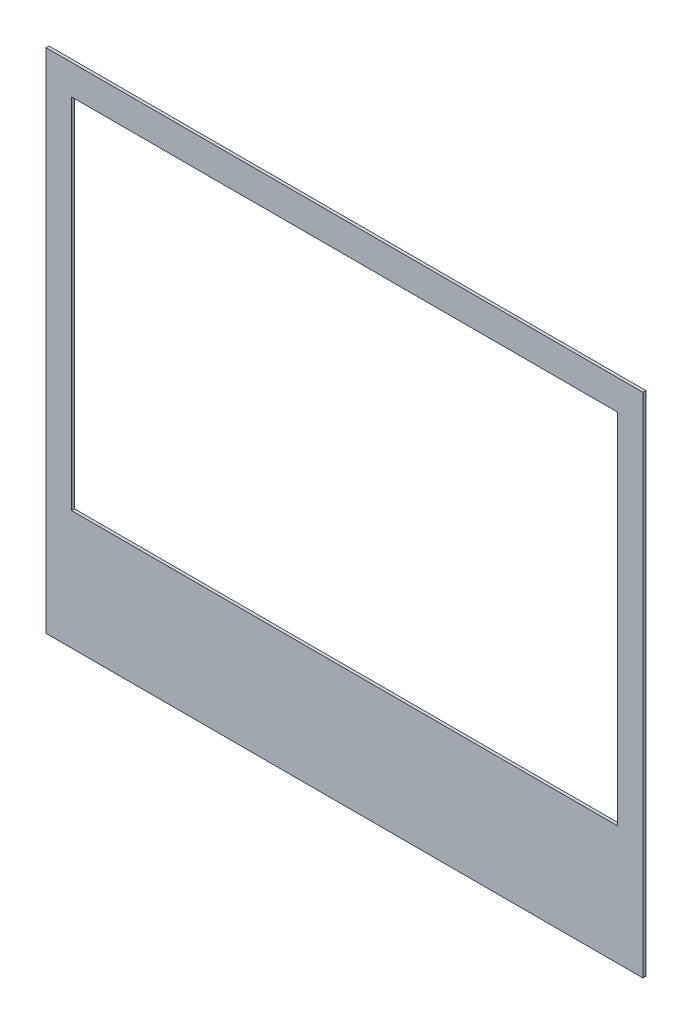
from build123d import *

# Parameters (mm, degrees)
ESBO_O1_W                = 39.98
ESBO_O1_H                = 33.98
ESBO_O1_W_2              = 36.58
ESBO_O1_H_2              = 24
RESSALTO_EXTRUS_O1_DEPTH = 0.2


with BuildPart() as part:
    # Esboço1 → Ressalto-extrusão1 (new body)
    with BuildSketch(Plane.XY):
        with Locations((19.99, 16.99)):
            Rectangle(ESBO_O1_W, ESBO_O1_H)
        with Locations((19.99, 19.98)):
            Rectangle(ESBO_O1_W_2, ESBO_O1_H_2, mode=Mode.SUBTRACT)
    extrude(amount=RESSALTO_EXTRUS_O1_DEPTH)


solid = part.part
